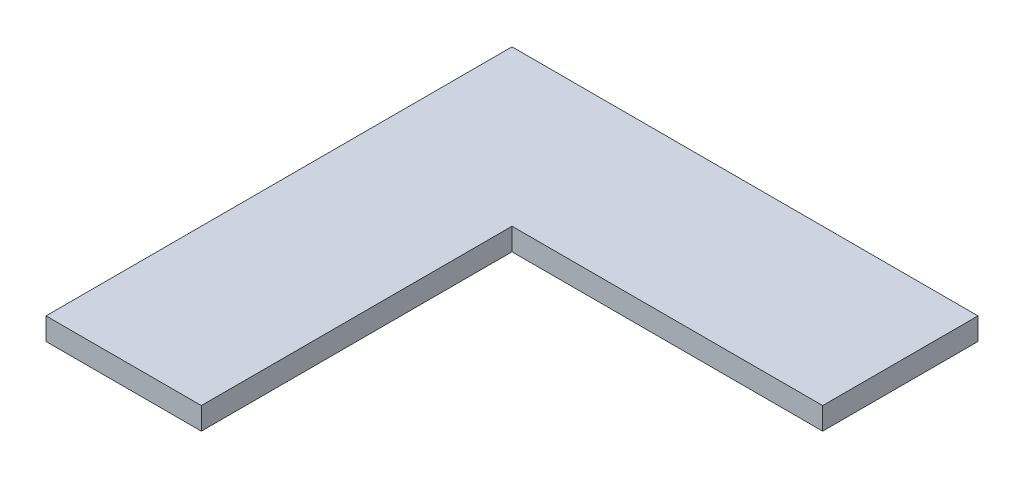
from build123d import *

# Parameters (mm, degrees)
BOSS_EXTRUDE1_DEPTH = 10


with BuildPart() as part:
    # Sketch1 → Boss-Extrude1 (new body)
    with BuildSketch(Plane(origin=(0, 0, 0), x_dir=(1, 0, 0), z_dir=(0, 1, 0))):
        Polygon((-105, -105), (-105, 105), (105, 105), (105, 35), (-35, 35), (-35, -105), align=None)
    extrude(amount=BOSS_EXTRUDE1_DEPTH)


solid = part.part
